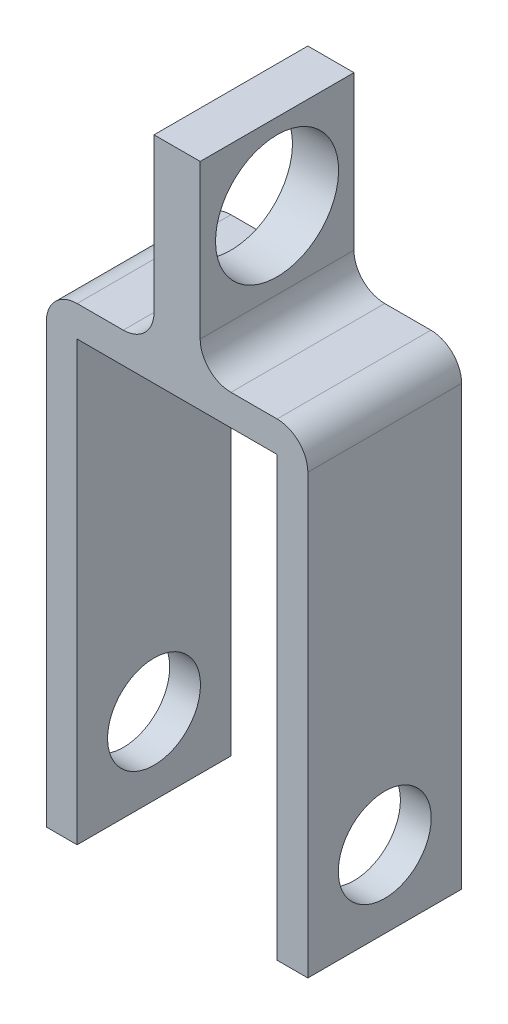
from build123d import *

# Parameters (mm, degrees)
SKETCH1_W               = 10
SKETCH1_H               = 142.4
SKETCH1_H_2             = 10
SKETCH1_W_2             = 25
SKETCH1_W_3             = 15
SKETCH1_H_3             = 60
BOSS_EXTRUDE1_DEPTH     = 50
FILLET1_R               = 10
SKETCH2_R               = 20
CUT_EXTRUDE1_DEPTH      = 36
CUT_EXTRUDE1_DEPTH_BACK = 51
SKETCH3_R               = 15.1
CUT_EXTRUDE2_DEPTH      = 1
CUT_EXTRUDE2_DEPTH_BACK = 86


with BuildPart() as part:
    # Sketch1 → Boss-Extrude1 (new body)
    with BuildSketch(Plane.XY):
        with Locations((-37.5, -106.2)):
            Rectangle(SKETCH1_W, SKETCH1_H)
        with Locations((-37.5, -30)):
            Rectangle(SKETCH1_W, SKETCH1_H_2)
        with Locations((-20, -30)):
            Rectangle(SKETCH1_W_2, SKETCH1_H_2)
        with Locations((0, -30)):
            Rectangle(SKETCH1_W_3, SKETCH1_H_2)
        with Locations((0, 5)):
            Rectangle(SKETCH1_W_3, SKETCH1_H_3)
        with Locations((20, -30)):
            Rectangle(SKETCH1_W_2, SKETCH1_H_2)
        with Locations((37.5, -30)):
            Rectangle(SKETCH1_W, SKETCH1_H_2)
        with Locations((37.5, -106.2)):
            Rectangle(SKETCH1_W, SKETCH1_H)
    extrude(amount=BOSS_EXTRUDE1_DEPTH)

    # Fillet1
    fillet1_edges = [part.edges().sort_by_distance(p)[0] for p in [
        (-42.5, -25, 25),
        (-7.5, -25, 25),
        (7.5, -25, 25),
        (42.5, -25, 25),
    ]]
    fillet(fillet1_edges, radius=FILLET1_R)

    # Sketch2 → Cut-Extrude1 (cut, two sides)
    with BuildSketch(Plane(origin=(7.5, 0, 0), x_dir=(0, 0, -1), z_dir=(1, 0, 0))) as cut_extrude1_sk:
        with Locations((-25, 10)):
            Circle(SKETCH2_R)
    extrude(amount=CUT_EXTRUDE1_DEPTH, mode=Mode.SUBTRACT)
    extrude(cut_extrude1_sk.sketch, amount=-CUT_EXTRUDE1_DEPTH_BACK, mode=Mode.SUBTRACT)

    # Sketch3 → Cut-Extrude2 (cut, two sides)
    with BuildSketch(Plane(origin=(42.5, 0, 0), x_dir=(0, 0, -1), z_dir=(1, 0, 0))) as cut_extrude2_sk:
        with Locations((-25, -152.4)):
            Circle(SKETCH3_R)
    extrude(amount=CUT_EXTRUDE2_DEPTH, mode=Mode.SUBTRACT)
    extrude(cut_extrude2_sk.sketch, amount=-CUT_EXTRUDE2_DEPTH_BACK, mode=Mode.SUBTRACT)


solid = part.part
